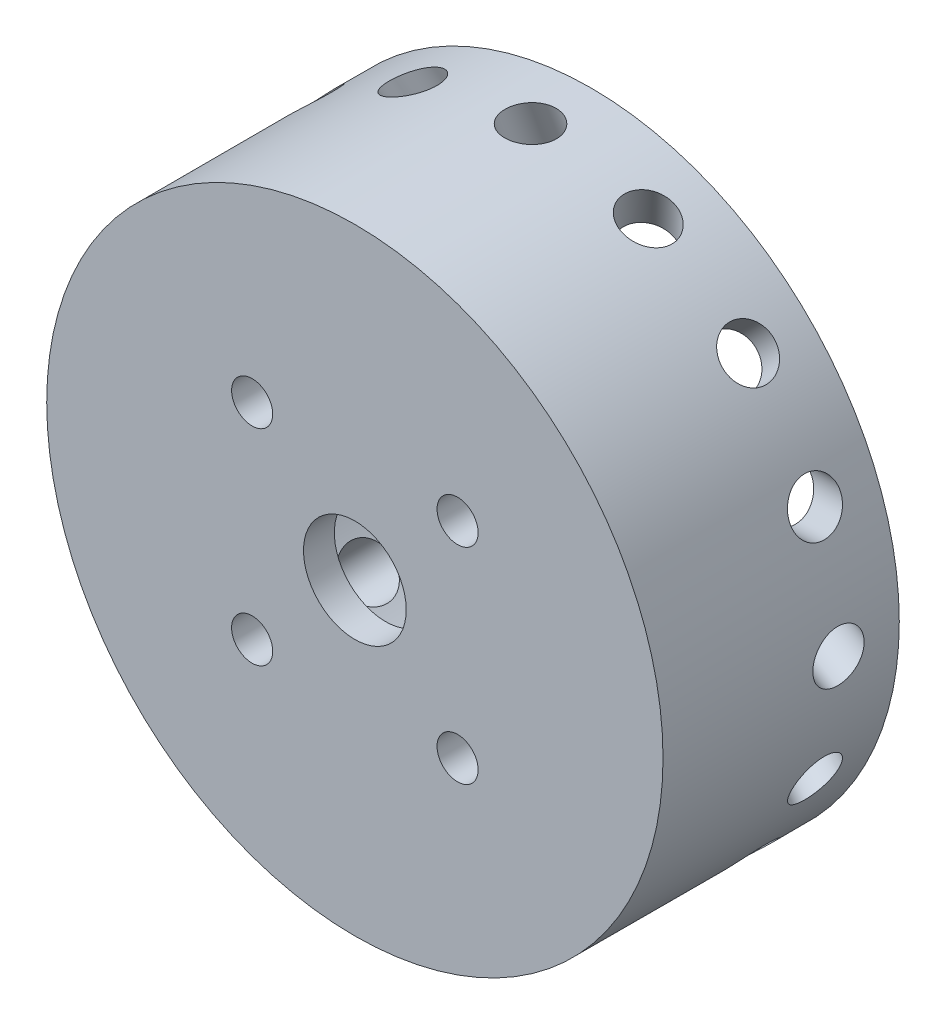
from build123d import *

# Parameters (mm, degrees)
ESQUISSE1_R                  = 30
ESQUISSE1_R_2                = 25
BOSS_EXTRU_1_DEPTH           = 20
ESQUISSE2_R                  = 30
BOSS_EXTRU_2_DEPTH           = 3
ESQUISSE4_R                  = 2
ENL_V_MAT_EXTRU_1_DEPTH      = 24
R_P_TITION_CIRCULAIRE1_COUNT = 4
ESQUISSE5_R                  = 2.5
R_P_TITION_CIRCULAIRE2_COUNT = 16
ESQUISSE7_R                  = 5
ENL_V_MAT_EXTRU_2_DEPTH      = 24


with BuildPart() as part:
    # Esquisse1 → Boss.-Extru.1 (new body)
    with BuildSketch(Plane.XY):
        Circle(ESQUISSE1_R)
        Circle(ESQUISSE1_R_2, mode=Mode.SUBTRACT)
    extrude(amount=BOSS_EXTRU_1_DEPTH)

    # Esquisse2 → Boss.-Extru.2 (add)
    with BuildSketch(Plane.XY.offset(20)):
        Circle(ESQUISSE2_R)
    extrude(amount=BOSS_EXTRU_2_DEPTH)

    # Esquisse4 → Enlèv. mat.-Extru.1 (cut, through all)
    with BuildSketch(Plane.XY.offset(23)):
        with Locations((10, 10)):
            Circle(ESQUISSE4_R)
    enl_v_mat_extru_1 = extrude(amount=-ENL_V_MAT_EXTRU_1_DEPTH, mode=Mode.SUBTRACT)

    # Répétition circulaire1: Enlèv. mat.-Extru.1 ×4 about axis
    r_p_tition_circulaire1_axis = Axis((0, 0, 0), (0, 0, 1))
    for i in range(1, R_P_TITION_CIRCULAIRE1_COUNT):
        add(enl_v_mat_extru_1.rotate(r_p_tition_circulaire1_axis, i * 360 / R_P_TITION_CIRCULAIRE1_COUNT), mode=Mode.SUBTRACT)

    # Enlèvement de matière-Balayage1: sweep along a path in Esquisse6
    with BuildLine(Plane(origin=(0, 0, 0), x_dir=(0, 0, -1), z_dir=(1, 0, 0))) as enl_vement_de_mati_re_balayage1_path:
        Line((4.919107, 0), (-6, -30))
    # Esquisse5 → Enlèvement de matière-Balayage1 (sweep, cut)
    with BuildSketch(Plane(origin=(0, 0, 0), x_dir=(1, 0, 0), z_dir=(0, 1, 0))):
        with Locations((0, 5)):
            Circle(ESQUISSE5_R)
    enl_vement_de_mati_re_balayage1 = sweep(path=enl_vement_de_mati_re_balayage1_path.line, mode=Mode.SUBTRACT)

    # Répétition circulaire2: Enlèvement de matière-Balayage1 ×16 about axis
    r_p_tition_circulaire2_axis = Axis((0, 0, 20), (0, 0, -1))
    for i in range(1, R_P_TITION_CIRCULAIRE2_COUNT):
        add(enl_vement_de_mati_re_balayage1.rotate(r_p_tition_circulaire2_axis, i * 360 / R_P_TITION_CIRCULAIRE2_COUNT), mode=Mode.SUBTRACT)

    # Esquisse7 → Enlèv. mat.-Extru.2 (cut, through all)
    with BuildSketch(Plane.XY.offset(23)):
        Circle(ESQUISSE7_R)
    extrude(amount=-ENL_V_MAT_EXTRU_2_DEPTH, mode=Mode.SUBTRACT)


solid = part.part
